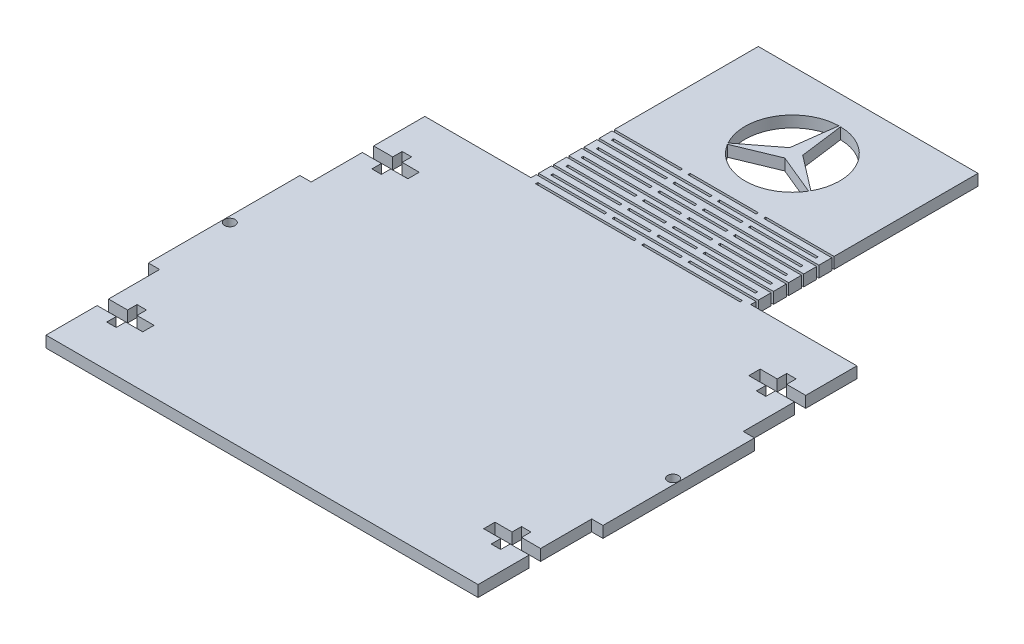
from build123d import *

# Parameters (mm, degrees)
EXTRUDE_1_DEPTH            = 2.9718
SKETCH_3_W                 = 1
SKETCH_3_H                 = 60
CUT_EXTRUDE_1_DEPTH        = 26
SKETCH_5_W                 = 18
SKETCH_5_H                 = 0.6
CUT_EXTRUDE_2_DEPTH        = 26
PATTERN_LINEAR_1_COUNT     = 4
PATTERN_LINEAR_1_PITCH     = 4
PATTERN_LINEAR_1_COL_COUNT = 3
PATTERN_LINEAR_1_COL_PITCH = 4
MIRROR_2_COPY_1_SKETCH_W   = 18
MIRROR_2_COPY_1_SKETCH_H   = 0.6
MIRROR_2_COPY_1_DEPTH      = 26
MIRROR_2_COPY_2_SKETCH_W   = 18
MIRROR_2_COPY_2_SKETCH_H   = 0.6
MIRROR_2_COPY_2_DEPTH      = 26
MIRROR_2_COPY_3_SKETCH_W   = 18
MIRROR_2_COPY_3_SKETCH_H   = 0.6
MIRROR_2_COPY_3_DEPTH      = 26
MIRROR_2_COPY_4_SKETCH_W   = 18
MIRROR_2_COPY_4_SKETCH_H   = 0.6
MIRROR_2_COPY_4_DEPTH      = 26
MIRROR_2_COPY_5_SKETCH_W   = 18
MIRROR_2_COPY_5_SKETCH_H   = 0.6
MIRROR_2_COPY_5_DEPTH      = 26
SKETCH_7_W                 = 18
SKETCH_7_H                 = 0.6
CUT_EXTRUDE_3_DEPTH        = 26
PATTERN_LINEAR_2_COUNT     = 6
PATTERN_LINEAR_2_PITCH     = 4
SKETCH_8_W                 = 26
SKETCH_8_H                 = 0.6
CUT_EXTRUDE_4_DEPTH        = 26
PATTERN_LINEAR_3_COUNT     = 6
PATTERN_LINEAR_3_PITCH     = 4
CUT_EXTRUDE_5_DEPTH        = 26
SKETCH_10_W                = 40
SKETCH_10_H                = 60
CUT_EXTRUDE_6_DEPTH        = 10
SKETCH_11_W                = 2.9718
SKETCH_11_H                = 30
CUT_EXTRUDE_7_DEPTH        = 10
SKETCH_12_R                = 1.4
CUT_EXTRUDE_8_DEPTH        = 10
CUT_EXTRUDE_9_DEPTH        = 10
PATTERN_LINEAR_4_COUNT     = 2
PATTERN_LINEAR_4_PITCH     = 70
MIRROR_5_COPY_1_DEPTH      = 10


with BuildPart() as part:
    # 草图1 → 凸台-拉伸1 (new body)
    with BuildSketch(Plane(origin=(0, 0, 0), x_dir=(1, 0, 0), z_dir=(0, 1, 0))):
        Polygon((60, -80), (60, 80), (-60, 80), (-60, 70), (-60, 63.47826087), (-60, 56.956521739), (-60, 50.434782609), (-60, 43.913043478), (-60, 37.391304348), (-60, 30.869565217), (-60, 24.347826087), (-60, 17.826086957), (-60, 11.304347826), (-60, 4.782608696), (-60, -1.739130435), (-60, -8.260869565), (-60, -14.782608696), (-60, -21.304347826), (-60, -27.826086957), (-60, -34.347826087), (-60, -40.869565217), (-60, -47.391304348), (-60, -53.913043478), (-60, -60.434782609), (-60, -66.956521739), (-60, -73.47826087), (-60, -80), align=None)
    extrude(amount=EXTRUDE_1_DEPTH)

    # 草图3 → 切除-拉伸1 (cut)
    with BuildSketch(Plane(origin=(0, 2.9718, 0), x_dir=(1, 0, 0), z_dir=(0, 1, 0))):
        with Locations((-29.5, 50)):
            Rectangle(SKETCH_3_W, SKETCH_3_H)
    cut_extrude_1 = extrude(amount=-CUT_EXTRUDE_1_DEPTH, mode=Mode.SUBTRACT)

    # 草图5 → 切除-拉伸2 (cut)
    with BuildSketch(Plane(origin=(0, 2.9718, 0), x_dir=(1, 0, 0), z_dir=(0, 1, 0))):
        with Locations((-20, 29.7)):
            Rectangle(SKETCH_5_W, SKETCH_5_H)
    cut_extrude_2 = extrude(amount=-CUT_EXTRUDE_2_DEPTH, mode=Mode.SUBTRACT)

    # 阵列(线性)1: 切除-拉伸2 ×4
    with Locations(*[(0, 0, -i * PATTERN_LINEAR_1_PITCH) for i in range(1, PATTERN_LINEAR_1_COUNT)]):
        add(cut_extrude_2, mode=Mode.SUBTRACT)

    # 阵列(线性)1 col: 切除-拉伸2 ×3
    with Locations(*[(0, 0, i * PATTERN_LINEAR_1_COL_PITCH) for i in range(1, PATTERN_LINEAR_1_COL_COUNT)]):
        add(cut_extrude_2, mode=Mode.SUBTRACT)

    # 镜向2: 切除-拉伸1, 切除-拉伸2 across plane
    add(cut_extrude_1.mirror(Plane(origin=(0, 0, 0), x_dir=(0, 0, 1), z_dir=(1, 0, 0))), mode=Mode.SUBTRACT)
    add(cut_extrude_2.mirror(Plane(origin=(0, 0, 0), x_dir=(0, 0, 1), z_dir=(1, 0, 0))), mode=Mode.SUBTRACT)

    # 镜向2 copy 1 sketch → 镜向2 copy 1 (cut)
    with BuildSketch(Plane(origin=(0, 2.9718, -4), x_dir=(-1, 0, 0), z_dir=(0, 1, 0))):
        with Locations((-20, -29.7)):
            Rectangle(MIRROR_2_COPY_1_SKETCH_W, MIRROR_2_COPY_1_SKETCH_H)
    extrude(amount=-MIRROR_2_COPY_1_DEPTH, mode=Mode.SUBTRACT)

    # 镜向2 copy 2 sketch → 镜向2 copy 2 (cut)
    with BuildSketch(Plane(origin=(0, 2.9718, -8), x_dir=(-1, 0, 0), z_dir=(0, 1, 0))):
        with Locations((-20, -29.7)):
            Rectangle(MIRROR_2_COPY_2_SKETCH_W, MIRROR_2_COPY_2_SKETCH_H)
    extrude(amount=-MIRROR_2_COPY_2_DEPTH, mode=Mode.SUBTRACT)

    # 镜向2 copy 3 sketch → 镜向2 copy 3 (cut)
    with BuildSketch(Plane(origin=(0, 2.9718, -12), x_dir=(-1, 0, 0), z_dir=(0, 1, 0))):
        with Locations((-20, -29.7)):
            Rectangle(MIRROR_2_COPY_3_SKETCH_W, MIRROR_2_COPY_3_SKETCH_H)
    extrude(amount=-MIRROR_2_COPY_3_DEPTH, mode=Mode.SUBTRACT)

    # 镜向2 copy 4 sketch → 镜向2 copy 4 (cut)
    with BuildSketch(Plane(origin=(0, 2.9718, 4), x_dir=(-1, 0, 0), z_dir=(0, 1, 0))):
        with Locations((-20, -29.7)):
            Rectangle(MIRROR_2_COPY_4_SKETCH_W, MIRROR_2_COPY_4_SKETCH_H)
    extrude(amount=-MIRROR_2_COPY_4_DEPTH, mode=Mode.SUBTRACT)

    # 镜向2 copy 5 sketch → 镜向2 copy 5 (cut)
    with BuildSketch(Plane(origin=(0, 2.9718, 8), x_dir=(-1, 0, 0), z_dir=(0, 1, 0))):
        with Locations((-20, -29.7)):
            Rectangle(MIRROR_2_COPY_5_SKETCH_W, MIRROR_2_COPY_5_SKETCH_H)
    extrude(amount=-MIRROR_2_COPY_5_DEPTH, mode=Mode.SUBTRACT)

    # 草图7 → 切除-拉伸3 (cut)
    with BuildSketch(Plane(origin=(0, 2.9718, 0), x_dir=(1, 0, 0), z_dir=(0, 1, 0))):
        with Locations((0, 41.7)):
            Rectangle(SKETCH_7_W, SKETCH_7_H)
    cut_extrude_3 = extrude(amount=-CUT_EXTRUDE_3_DEPTH, mode=Mode.SUBTRACT)

    # 阵列(线性)2: 切除-拉伸3 ×6
    with Locations(*[(0, 0, i * PATTERN_LINEAR_2_PITCH) for i in range(1, PATTERN_LINEAR_2_COUNT)]):
        add(cut_extrude_3, mode=Mode.SUBTRACT)

    # 草图8 → 切除-拉伸4 (cut)
    with BuildSketch(Plane(origin=(0, 2.9718, 0), x_dir=(1, 0, 0), z_dir=(0, 1, 0))):
        with Locations((-14, 39.5)):
            Rectangle(SKETCH_8_W, SKETCH_8_H)
        with Locations((14, 39.5)):
            Rectangle(SKETCH_8_W, SKETCH_8_H)
    cut_extrude_4 = extrude(amount=-CUT_EXTRUDE_4_DEPTH, mode=Mode.SUBTRACT)

    # 阵列(线性)3: 切除-拉伸4 ×6
    with Locations(*[(0, 0, i * PATTERN_LINEAR_3_PITCH) for i in range(1, PATTERN_LINEAR_3_COUNT)]):
        add(cut_extrude_4, mode=Mode.SUBTRACT)

    # 草图9 → 切除-拉伸5 (cut)
    with BuildSketch(Plane(origin=(0, 2.9718, 0), x_dir=(1, 0, 0), z_dir=(0, 1, 0))):
        with BuildLine():
            Line((-10.932815665, 53.940004815), (-1.732050808, 61))
            Line((-1.732050808, 61), (-0.218298055, 72.498093693))
            ThreePointArc((-0.218298055, 72.498093693), (-10.825317547, 66.25), (-10.932815665, 53.940004815))
        make_face()
        with BuildLine():
            Line((0.218298055, 72.498093693), (1.732050808, 61))
            Line((1.732050808, 61), (10.932815665, 53.940004815))
            ThreePointArc((10.932815665, 53.940004815), (12.101863406, 56.87031917), (12.5, 60))
            ThreePointArc((12.5, 60), (8.915680728, 68.761314807), (0.218298055, 72.498093693))
        make_face()
        with BuildLine():
            Line((10.714517609, 53.561901492), (0, 58))
            Line((0, 58), (-10.714517609, 53.561901492))
            ThreePointArc((-10.714517609, 53.561901492), (0, 47.5), (10.714517609, 53.561901492))
        make_face()
    extrude(amount=-CUT_EXTRUDE_5_DEPTH, mode=Mode.SUBTRACT)

    # 草图10 → 切除-拉伸6 (cut)
    with BuildSketch(Plane(origin=(0, 2.9718, 0), x_dir=(1, 0, 0), z_dir=(0, 1, 0))):
        with Locations((-50, 50)):
            Rectangle(SKETCH_10_W, SKETCH_10_H)
    cut_extrude_6 = extrude(amount=-CUT_EXTRUDE_6_DEPTH, mode=Mode.SUBTRACT)

    # 镜向3: 切除-拉伸6 across plane
    add(cut_extrude_6.mirror(Plane(origin=(0, 0, 0), x_dir=(0, 0, 1), z_dir=(1, 0, 0))), mode=Mode.SUBTRACT)

    # 草图11 → 切除-拉伸7 (cut)
    with BuildSketch(Plane(origin=(0, 2.9718, 0), x_dir=(1, 0, 0), z_dir=(0, 1, 0))):
        with Locations((-58.5141, 5)):
            Rectangle(SKETCH_11_W, SKETCH_11_H)
        with Locations((-58.5141, -65)):
            Rectangle(SKETCH_11_W, SKETCH_11_H)
    cut_extrude_7 = extrude(amount=-CUT_EXTRUDE_7_DEPTH, mode=Mode.SUBTRACT)

    # 镜向4: 切除-拉伸7 across plane
    add(cut_extrude_7.mirror(Plane(origin=(0, 0, 0), x_dir=(0, 0, 1), z_dir=(1, 0, 0))), mode=Mode.SUBTRACT)

    # 草图12 → 切除-拉伸8 (cut)
    with BuildSketch(Plane(origin=(0, 2.9718, 0), x_dir=(1, 0, 0), z_dir=(0, 1, 0))):
        with Locations((-58.5, -30)):
            Circle(SKETCH_12_R)
    cut_extrude_8 = extrude(amount=-CUT_EXTRUDE_8_DEPTH, mode=Mode.SUBTRACT)

    # 草图13 → 切除-拉伸9 (cut)
    with BuildSketch(Plane(origin=(0, 2.9718, 0), x_dir=(1, 0, 0), z_dir=(0, 1, 0))):
        Polygon((-60, 6.5), (-60, 5), (-45, 5), (-45, 6.5), (-49.5, 6.5), (-49.5, 9), (-52, 9), (-52, 6.5), align=None)
        Polygon((-60, 5), (-60, 3.5), (-52, 3.5), (-52, 1), (-49.5, 1), (-49.5, 3.5), (-45, 3.5), (-45, 5), align=None)
    cut_extrude_9 = extrude(amount=-CUT_EXTRUDE_9_DEPTH, mode=Mode.SUBTRACT)

    # 阵列(线性)4: 切除-拉伸9 ×2
    with Locations(*[(0, 0, i * PATTERN_LINEAR_4_PITCH) for i in range(1, PATTERN_LINEAR_4_COUNT)]):
        add(cut_extrude_9, mode=Mode.SUBTRACT)

    # 镜向5: 切除-拉伸9 across plane
    add(cut_extrude_9.mirror(Plane(origin=(0, 0, 0), x_dir=(0, 0, 1), z_dir=(1, 0, 0))), mode=Mode.SUBTRACT)

    # 镜向5 copy 1 sketch → 镜向5 copy 1 (cut)
    with BuildSketch(Plane(origin=(0, 2.9718, 70), x_dir=(-1, 0, 0), z_dir=(0, 1, 0))):
        Polygon((-60, -6.5), (-60, -5), (-45, -5), (-45, -6.5), (-49.5, -6.5), (-49.5, -9), (-52, -9), (-52, -6.5), align=None)
        Polygon((-60, -5), (-60, -3.5), (-52, -3.5), (-52, -1), (-49.5, -1), (-49.5, -3.5), (-45, -3.5), (-45, -5), align=None)
    extrude(amount=-MIRROR_5_COPY_1_DEPTH, mode=Mode.SUBTRACT)

    # 镜向6: 切除-拉伸8 across plane
    add(cut_extrude_8.mirror(Plane(origin=(0, 0, 0), x_dir=(0, 0, 1), z_dir=(1, 0, 0))), mode=Mode.SUBTRACT)


solid = part.part
